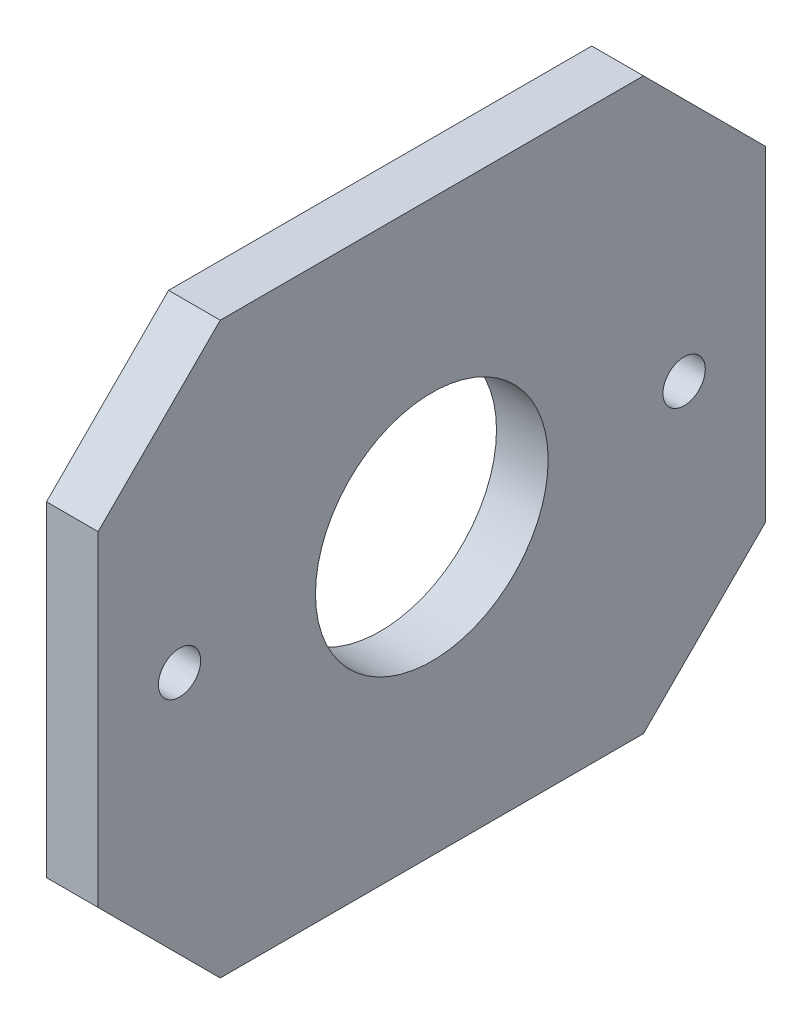
from build123d import *

# Parameters (mm, degrees)
SKETCH1_W           = 82
SKETCH1_H           = 70
SKETCH1_R           = 14.295
SKETCH1_R_2         = 2.6
BOSS_EXTRUDE1_DEPTH = 6.35
CHAMFER1_SIZE       = 15


with BuildPart() as part:
    # Sketch1 → Boss-Extrude1 (new body)
    with BuildSketch(Plane(origin=(0, 0, 0), x_dir=(0, 0, -1), z_dir=(1, 0, 0))):
        Rectangle(SKETCH1_W, SKETCH1_H)
        Circle(SKETCH1_R, mode=Mode.SUBTRACT)
        with Locations((-31, 0)):
            Circle(SKETCH1_R_2, mode=Mode.SUBTRACT)
        with Locations((31, 0)):
            Circle(SKETCH1_R_2, mode=Mode.SUBTRACT)
    extrude(amount=BOSS_EXTRUDE1_DEPTH)

    # Chamfer1
    chamfer1_edges = [part.edges().sort_by_distance(p)[0] for p in [
        (3.175, 35, 41),
        (3.175, 35, -41),
        (3.175, -35, -41),
        (3.175, -35, 41),
    ]]
    chamfer(chamfer1_edges, length=CHAMFER1_SIZE)


solid = part.part
